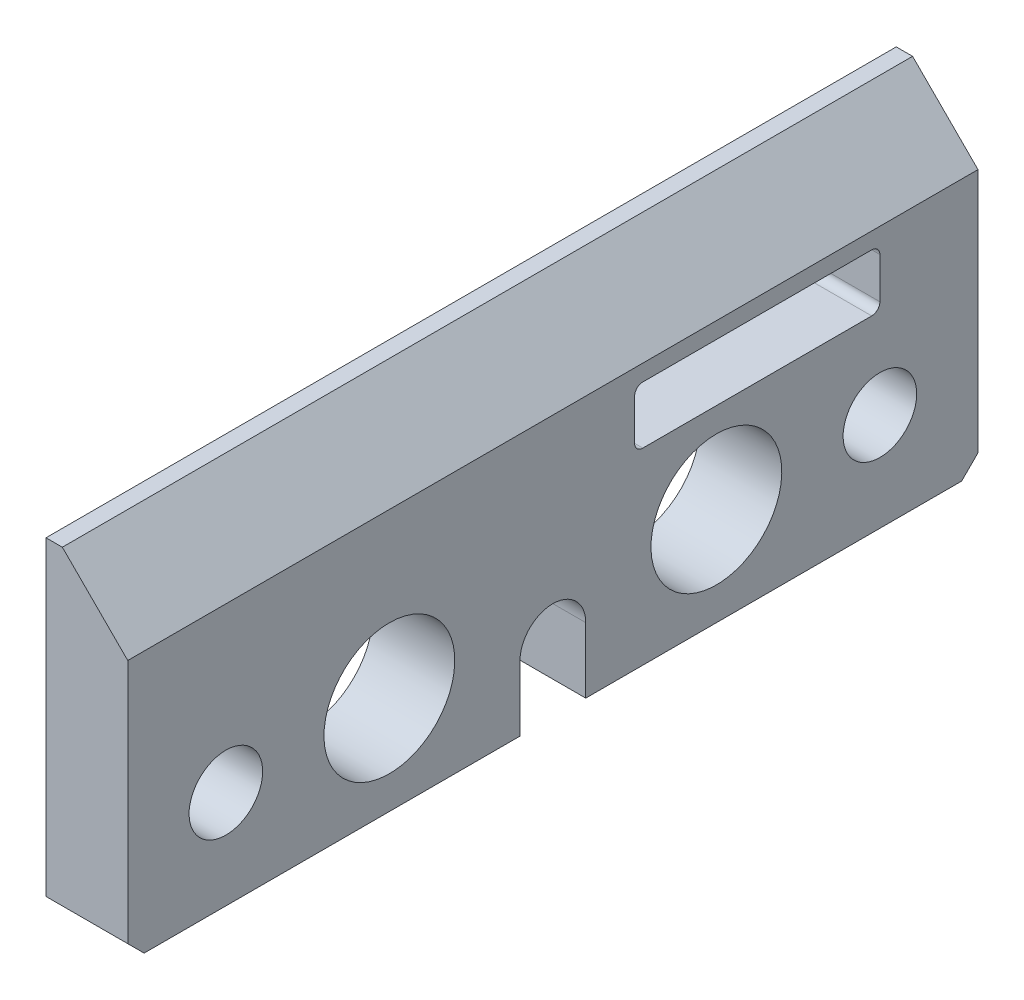
from build123d import *

# Parameters (mm, degrees)
SKETCH1_W           = 5
SKETCH1_H           = 20
BOSS_EXTRUDE1_DEPTH = 52
SKETCH2_R           = 2.25
SKETCH2_R_2         = 4
SKETCH2_W           = 15
SKETCH2_H           = 3.5
CUT_EXTRUDE1_DEPTH  = 52
FILLET1_R           = 0.5
CHAMFER1_SIZE       = 1
CHAMFER2_SIZE       = 4


with BuildPart() as part:
    # Sketch1 → Boss-Extrude1 (new body)
    with BuildSketch(Plane.XY):
        with Locations((1.671974522, -6.576433121)):
            Rectangle(SKETCH1_W, SKETCH1_H)
    extrude(amount=BOSS_EXTRUDE1_DEPTH)

    # Sketch2 → Cut-Extrude1 (cut)
    with BuildSketch(Plane(origin=(4.171974522, 0, 0), x_dir=(0, 0, -1), z_dir=(1, 0, 0))):
        with Locations((-46, -10.576433121)):
            Circle(SKETCH2_R)
        with Locations((-36, -10.576433121)):
            Circle(SKETCH2_R_2)
        with Locations((-16, -10.576433121)):
            Circle(SKETCH2_R_2)
        with Locations((-6, -10.576433121)):
            Circle(SKETCH2_R)
        with BuildLine():
            Line((-23.99, -16.576433121), (-28.01, -16.576433121))
            Line((-28.01, -16.576433121), (-28.01, -12.576433121))
            ThreePointArc((-28.01, -12.576433121), (-26, -10.566433121), (-23.99, -12.576433121))
            Line((-23.99, -12.576433121), (-23.99, -16.576433121))
        make_face()
        with Locations((-13.5, -3.326433121)):
            Rectangle(SKETCH2_W, SKETCH2_H)
    extrude(amount=-CUT_EXTRUDE1_DEPTH, mode=Mode.SUBTRACT)

    # Fillet1
    fillet1_edges = [part.edges().sort_by_distance(p)[0] for p in [
        (1.671974522, -5.076433121, 21),
        (1.671974522, -1.576433121, 21),
        (1.671974522, -1.576433121, 6),
        (1.671974522, -5.076433121, 6),
    ]]
    fillet(fillet1_edges, radius=FILLET1_R)

    # Chamfer1
    chamfer1_edges = [part.edges().sort_by_distance(p)[0] for p in [
        (1.671974522, -16.576433121, 0),
        (1.671974522, -16.576433121, 52),
    ]]
    chamfer(chamfer1_edges, length=CHAMFER1_SIZE)

    # Chamfer2
    chamfer2_edges = [part.edges().sort_by_distance(p)[0] for p in [
        (4.171974522, 3.423566879, 26),
    ]]
    chamfer(chamfer2_edges, length=CHAMFER2_SIZE)


solid = part.part
